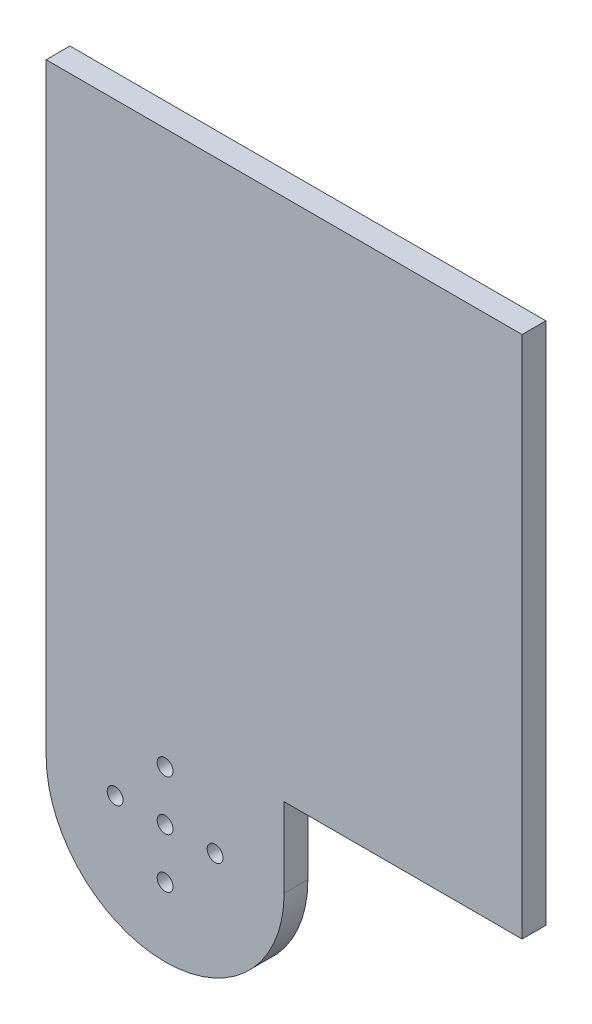
from build123d import *

# Parameters (mm, degrees)
SKETCH_1_R      = 15
SKETCH_1_R_2    = 1
EXTRUDE_1_DEPTH = 3
SKETCH_2_W      = 3
SKETCH_2_H      = 66
EXTRUDE_2_DEPTH = 30


with BuildPart() as part:
    # 草圖1 → 填料-伸長1 (new body)
    with BuildSketch(Plane.XY):
        Circle(SKETCH_1_R)
        with Locations((0, 6.3)):
            Circle(SKETCH_1_R_2, mode=Mode.SUBTRACT)
        with Locations((-6.3, 0)):
            Circle(SKETCH_1_R_2, mode=Mode.SUBTRACT)
        with Locations((0, -6.3)):
            Circle(SKETCH_1_R_2, mode=Mode.SUBTRACT)
        with Locations((6.3, 0)):
            Circle(SKETCH_1_R_2, mode=Mode.SUBTRACT)
        Circle(SKETCH_1_R_2, mode=Mode.SUBTRACT)
        with BuildLine():
            Line((-15, 76), (-15, 0))
            ThreePointArc((-15, 0), (0, 15), (15, 0))
            Line((15, 0), (15, 76))
            Line((15, 76), (-15, 76))
        make_face()
    extrude(amount=-EXTRUDE_1_DEPTH)

    # 草圖2 → 填料-伸長2 (add)
    with BuildSketch(Plane(origin=(15, 0, 0), x_dir=(0, 0, -1), z_dir=(1, 0, 0))):
        with Locations((1.5, 43)):
            Rectangle(SKETCH_2_W, SKETCH_2_H)
    extrude(amount=EXTRUDE_2_DEPTH)


solid = part.part
